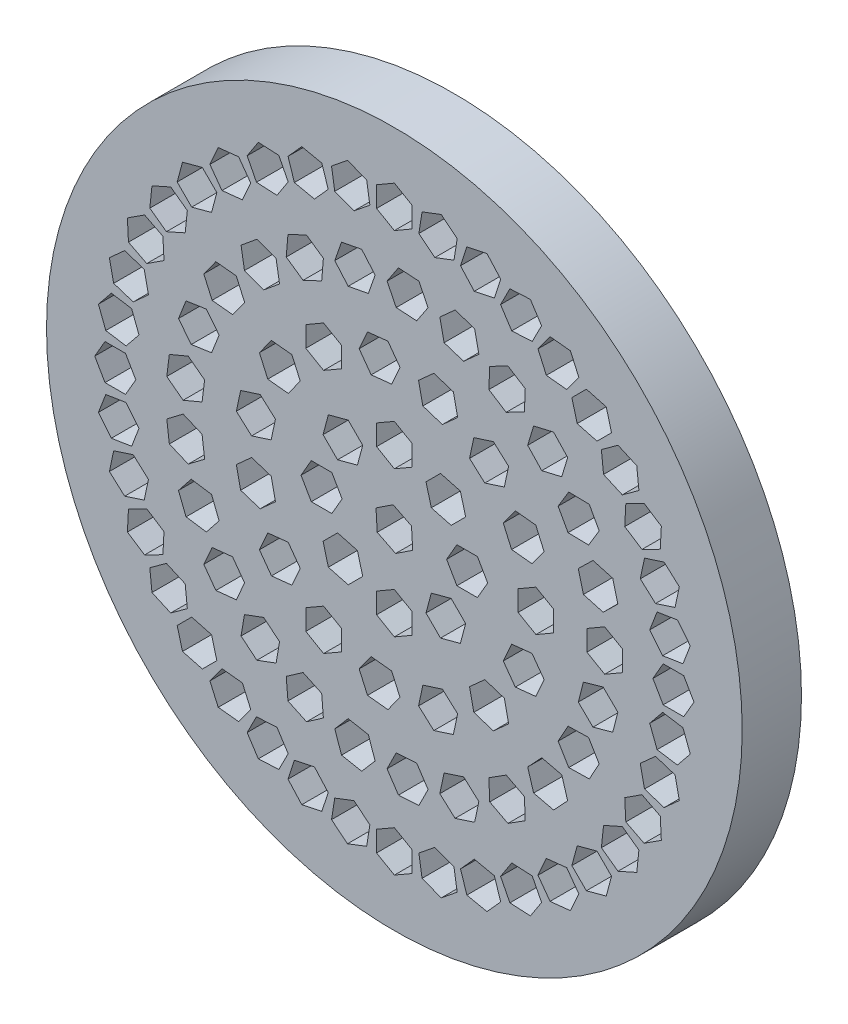
from build123d import *

# Parameters (mm, degrees)
SKETCH1_R           = 29.34
BOSS_EXTRUDE1_DEPTH = 5


with BuildPart() as part:
    # Sketch1 → Boss-Extrude1 (new body)
    with BuildSketch(Plane.XY):
        Circle(SKETCH1_R)
        Polygon((3.116890765, -3.116890765), (2.668603029, -4.789923373), (3.8933479, -6.014668244), (5.566380508, -5.566380508), (6.014668244, -3.8933479), (4.789923373, -2.668603029), align=None, mode=Mode.SUBTRACT)
        Polygon((7.872050808, 0), (7.006025404, 1.5), (5.273974596, 1.5), (4.407949192, 0), (5.273974596, -1.5), (7.006025404, -1.5), align=None, mode=Mode.SUBTRACT)
        Polygon((11.94, -1.732050808), (13.44, -0.866025404), (13.44, 0.866025404), (11.94, 1.732050808), (10.44, 0.866025404), (10.44, -0.866025404), align=None, mode=Mode.SUBTRACT)
        Polygon((17.74, -1.732050808), (19.24, -0.866025404), (19.24, 0.866025404), (17.74, 1.732050808), (16.24, 0.866025404), (16.24, -0.866025404), align=None, mode=Mode.SUBTRACT)
        Polygon((21.807949192, 0), (22.673974596, -1.5), (24.406025404, -1.5), (25.272050808, 0), (24.406025404, 1.5), (22.673974596, 1.5), align=None, mode=Mode.SUBTRACT)
        Polygon((0, -4.407949192), (-1.5, -5.273974596), (-1.5, -7.006025404), (0, -7.872050808), (1.5, -7.006025404), (1.5, -5.273974596), align=None, mode=Mode.SUBTRACT)
        Polygon((-3.116890765, -3.116890765), (-4.789923373, -2.668603029), (-6.014668244, -3.8933479), (-5.566380508, -5.566380508), (-3.8933479, -6.014668244), (-2.668603029, -4.789923373), align=None, mode=Mode.SUBTRACT)
        Polygon((-4.407949192, 0), (-5.273974596, 1.5), (-7.006025404, 1.5), (-7.872050808, 0), (-7.006025404, -1.5), (-5.273974596, -1.5), align=None, mode=Mode.SUBTRACT)
        Polygon((-3.116890765, 3.116890765), (-2.668603029, 4.789923373), (-3.8933479, 6.014668244), (-5.566380508, 5.566380508), (-6.014668244, 3.8933479), (-4.789923373, 2.668603029), align=None, mode=Mode.SUBTRACT)
        Polygon((0, 4.407949192), (1.5, 5.273974596), (1.5, 7.006025404), (0, 7.872050808), (-1.5, 7.006025404), (-1.5, 5.273974596), align=None, mode=Mode.SUBTRACT)
        Polygon((3.116890765, 3.116890765), (4.789923373, 2.668603029), (6.014668244, 3.8933479), (5.566380508, 5.566380508), (3.8933479, 6.014668244), (2.668603029, 4.789923373), align=None, mode=Mode.SUBTRACT)
        Polygon((9.185170312, -5.037484128), (10.203244233, -6.438742666), (11.925806685, -6.257694057), (12.630295216, -4.675386909), (11.612221295, -3.274128371), (9.889658843, -3.45517698), align=None, mode=Mode.SUBTRACT)
        Polygon((1.549193338, -0.774596669), (1.445417062, 0.954342452), (-0.103776276, 1.728939121), (-1.549193338, 0.774596669), (-1.445417062, -0.954342452), (0.103776276, -1.728939121), align=None, mode=Mode.SUBTRACT)
        Polygon((6.342141233, -8.337916082), (6.702254845, -10.032117423), (8.349533052, -10.567350558), (9.636697647, -9.408382351), (9.276584035, -7.714181009), (7.629305828, -7.178947874), align=None, mode=Mode.SUBTRACT)
        Polygon((2.402498318, -10.196646597), (2.042384706, -11.890847939), (3.329549301, -13.049816146), (4.976827508, -12.514583012), (5.33694112, -10.82038167), (4.049776525, -9.661413463), align=None, mode=Mode.SUBTRACT)
        Polygon((-1.952558383, -10.292284283), (-2.970632303, -11.693542821), (-2.266143772, -13.275849969), (-0.54358132, -13.456898578), (0.474492601, -12.05564004), (-0.229995931, -10.473332892), align=None, mode=Mode.SUBTRACT)
        Polygon((-5.97, -8.608292514), (-7.47, -9.474317917), (-7.47, -11.206368725), (-5.97, -12.072394129), (-4.47, -11.206368725), (-4.47, -9.474317917), align=None, mode=Mode.SUBTRACT)
        Polygon((-8.955174382, -5.435848765), (-10.677736834, -5.616897374), (-11.382225365, -7.199204522), (-10.364151444, -8.60046306), (-8.641588992, -8.419414451), (-7.937100461, -6.837107303), align=None, mode=Mode.SUBTRACT)
        Polygon((-10.391917758, -1.323497381), (-12.039195965, -0.788264247), (-13.32636056, -1.947232454), (-12.966246948, -3.641433795), (-11.318968741, -4.17666693), (-10.031804146, -3.017698723), align=None, mode=Mode.SUBTRACT)
        Polygon((-10.031804146, 3.017698723), (-11.318968741, 4.17666693), (-12.966246948, 3.641433795), (-13.32636056, 1.947232454), (-12.039195965, 0.788264247), (-10.391917758, 1.323497381), align=None, mode=Mode.SUBTRACT)
        Polygon((-7.937100461, 6.837107303), (-8.641588992, 8.419414451), (-10.364151444, 8.60046306), (-11.382225365, 7.199204522), (-10.677736834, 5.616897374), (-8.955174382, 5.435848765), align=None, mode=Mode.SUBTRACT)
        Polygon((-4.47, 9.474317917), (-4.47, 11.206368725), (-5.97, 12.072394129), (-7.47, 11.206368725), (-7.47, 9.474317917), (-5.97, 8.608292514), align=None, mode=Mode.SUBTRACT)
        Polygon((-0.229995931, 10.473332892), (0.474492601, 12.05564004), (-0.54358132, 13.456898578), (-2.266143772, 13.275849969), (-2.970632303, 11.693542821), (-1.952558383, 10.292284283), align=None, mode=Mode.SUBTRACT)
        Polygon((4.049776525, 9.661413463), (5.33694112, 10.82038167), (4.976827508, 12.514583012), (3.329549301, 13.049816146), (2.042384706, 11.890847939), (2.402498318, 10.196646597), align=None, mode=Mode.SUBTRACT)
        Polygon((7.629305828, 7.178947874), (9.276584035, 7.714181009), (9.636697647, 9.408382351), (8.349533052, 10.567350558), (6.702254845, 10.032117423), (6.342141233, 8.337916082), align=None, mode=Mode.SUBTRACT)
        Polygon((9.889658843, 3.45517698), (11.612221295, 3.274128371), (12.630295216, 4.675386909), (11.925806685, 6.257694057), (10.203244233, 6.438742666), (9.185170312, 5.037484128), align=None, mode=Mode.SUBTRACT)
        Polygon((16.751921759, -6.089393845), (18.42016826, -5.623611052), (18.85091178, -3.945975806), (17.613408798, -2.734123352), (15.945162297, -3.199906144), (15.514418777, -4.877541391), align=None, mode=Mode.SUBTRACT)
        Polygon((14.711258664, -10.064117871), (16.442929604, -10.027844536), (17.277351444, -8.510036843), (16.380102344, -7.028502486), (14.648431404, -7.064775821), (13.814009564, -8.582583514), align=None, mode=Mode.SUBTRACT)
        Polygon((11.746233083, -13.406476359), (13.432521208, -13.801991668), (14.618191575, -12.539380968), (14.117573818, -10.881254959), (12.431285693, -10.48573965), (11.245615326, -11.74835035), align=None, mode=Mode.SUBTRACT)
        Polygon((8.043148478, -15.906456631), (9.578098103, -16.708908903), (11.040516968, -15.78082967), (10.967986208, -14.050298165), (9.433036583, -13.247845894), (7.970617718, -14.175925127), align=None, mode=Mode.SUBTRACT)
        Polygon((3.834683273, -17.406975734), (5.121847868, -18.565943941), (6.769126075, -18.030710806), (7.129239687, -16.336509464), (5.842075092, -15.177541257), (4.194796885, -15.712774392), align=None, mode=Mode.SUBTRACT)
        Polygon((-0.614729184, -17.813750532), (0.343773095, -19.25641244), (2.072406096, -19.14765607), (2.842536817, -17.596237792), (1.884034538, -16.153575885), (0.155401537, -16.262332255), align=None, mode=Mode.SUBTRACT)
        Polygon((-5.025515947, -17.101221871), (-4.455902206, -18.736929725), (-2.75453078, -19.061483683), (-1.622773095, -17.750329785), (-2.192386836, -16.11462193), (-3.893758262, -15.790067973), align=None, mode=Mode.SUBTRACT)
        Polygon((-9.120531059, -15.314160545), (-8.975596783, -17.040136807), (-7.408390356, -17.777608172), (-5.986118205, -16.789103277), (-6.131052482, -15.063127015), (-7.698258908, -14.325655649), align=None, mode=Mode.SUBTRACT)
        Polygon((-12.642469663, -12.564854191), (-12.931321605, -14.272649423), (-11.596753521, -15.376700159), (-9.973333494, -14.772955663), (-9.684481551, -13.065160431), (-11.019049636, -11.961109695), align=None, mode=Mode.SUBTRACT)
        Polygon((-15.370035401, -9.026051837), (-16.074523932, -10.608358985), (-15.056450011, -12.009617523), (-13.333887559, -11.828568914), (-12.629399028, -10.246261766), (-13.647472949, -8.845003228), align=None, mode=Mode.SUBTRACT)
        Polygon((-17.131845288, -4.920109451), (-18.207704803, -6.277506337), (-17.570094374, -7.88792645), (-15.856624431, -8.140949678), (-14.780764916, -6.783552792), (-15.418375345, -5.173132679), align=None, mode=Mode.SUBTRACT)
        Polygon((-17.81719833, -0.505018494), (-19.196828617, -1.552214879), (-18.979745089, -3.270607949), (-17.383031273, -3.941804633), (-16.003400985, -2.894608248), (-16.220484514, -1.176215178), align=None, mode=Mode.SUBTRACT)
        Polygon((-17.383031273, 3.941804633), (-18.979745089, 3.270607949), (-19.196828617, 1.552214879), (-17.81719833, 0.505018494), (-16.220484514, 1.176215178), (-16.003400985, 2.894608248), align=None, mode=Mode.SUBTRACT)
        Polygon((-15.856624431, 8.140949678), (-17.570094374, 7.88792645), (-18.207704803, 6.277506337), (-17.131845288, 4.920109451), (-15.418375345, 5.173132679), (-14.780764916, 6.783552792), align=None, mode=Mode.SUBTRACT)
        Polygon((-13.333887559, 11.828568914), (-15.056450011, 12.009617523), (-16.074523932, 10.608358985), (-15.370035401, 9.026051837), (-13.647472949, 8.845003228), (-12.629399028, 10.246261766), align=None, mode=Mode.SUBTRACT)
        Polygon((-9.973333494, 14.772955663), (-11.596753521, 15.376700159), (-12.931321605, 14.272649423), (-12.642469663, 12.564854191), (-11.019049636, 11.961109695), (-9.684481551, 13.065160431), align=None, mode=Mode.SUBTRACT)
        Polygon((-5.986118205, 16.789103277), (-7.408390356, 17.777608172), (-8.975596783, 17.040136807), (-9.120531059, 15.314160545), (-7.698258908, 14.325655649), (-6.131052482, 15.063127015), align=None, mode=Mode.SUBTRACT)
        Polygon((-1.622773095, 17.750329785), (-2.75453078, 19.061483683), (-4.455902206, 18.736929725), (-5.025515947, 17.101221871), (-3.893758262, 15.790067973), (-2.192386836, 16.11462193), align=None, mode=Mode.SUBTRACT)
        Polygon((2.842536817, 17.596237792), (2.072406096, 19.14765607), (0.343773095, 19.25641244), (-0.614729184, 17.813750532), (0.155401537, 16.262332255), (1.884034538, 16.153575885), align=None, mode=Mode.SUBTRACT)
        Polygon((7.129239687, 16.336509464), (6.769126075, 18.030710806), (5.121847868, 18.565943941), (3.834683273, 17.406975734), (4.194796885, 15.712774392), (5.842075092, 15.177541257), align=None, mode=Mode.SUBTRACT)
        Polygon((10.967986208, 14.050298165), (11.040516968, 15.78082967), (9.578098103, 16.708908903), (8.043148478, 15.906456631), (7.970617718, 14.175925127), (9.433036583, 13.247845894), align=None, mode=Mode.SUBTRACT)
        Polygon((14.117573818, 10.881254959), (14.618191575, 12.539380968), (13.432521208, 13.801991668), (11.746233083, 13.406476359), (11.245615326, 11.74835035), (12.431285693, 10.48573965), align=None, mode=Mode.SUBTRACT)
        Polygon((16.380102344, 7.028502486), (17.277351444, 8.510036843), (16.442929604, 10.027844536), (14.711258664, 10.064117871), (13.814009564, 8.582583514), (14.648431404, 7.064775821), align=None, mode=Mode.SUBTRACT)
        Polygon((17.613408798, 2.734123352), (18.85091178, 3.945975806), (18.42016826, 5.623611052), (16.751921759, 6.089393845), (15.514418777, 4.877541391), (15.945162297, 3.199906144), align=None, mode=Mode.SUBTRACT)
        Polygon((21.53945715, -3.411514866), (22.160168646, -5.028523597), (23.870895034, -5.299476039), (24.960909926, -3.953419749), (24.340198429, -2.336411017), (22.629472041, -2.065458575), align=None, mode=Mode.SUBTRACT)
        Polygon((20.740592186, -6.739026913), (21.100705798, -8.433228255), (22.747984006, -8.968461389), (24.035148601, -7.809493182), (23.675034989, -6.11529184), (22.027756782, -5.580058706), align=None, mode=Mode.SUBTRACT)
        Polygon((19.43102501, -9.900601752), (19.521673545, -11.630278844), (21.064942115, -12.416613456), (22.517562149, -11.473270976), (22.426913614, -9.743593883), (20.883645044, -8.957259272), align=None, mode=Mode.SUBTRACT)
        Polygon((17.643001509, -12.818390918), (17.4619529, -14.54095337), (18.863211438, -15.559027291), (20.445518586, -14.85453876), (20.626567195, -13.131976308), (19.225308657, -12.113902387), align=None, mode=Mode.SUBTRACT)
        Polygon((15.420548758, -15.420548758), (14.972261022, -17.093581365), (16.197005893, -18.318326237), (17.870038501, -17.870038501), (18.318326237, -16.197005893), (17.093581365, -14.972261022), align=None, mode=Mode.SUBTRACT)
        Polygon((12.818390918, -17.643001509), (12.113902387, -19.225308657), (13.131976308, -20.626567195), (14.85453876, -20.445518586), (15.559027291, -18.863211438), (14.54095337, -17.4619529), align=None, mode=Mode.SUBTRACT)
        Polygon((9.900601752, -19.43102501), (8.957259272, -20.883645044), (9.743593883, -22.426913614), (11.473270976, -22.517562149), (12.416613456, -21.064942115), (11.630278844, -19.521673545), align=None, mode=Mode.SUBTRACT)
        Polygon((6.739026913, -20.740592186), (5.580058706, -22.027756782), (6.11529184, -23.675034989), (7.809493182, -24.035148601), (8.968461389, -22.747984006), (8.433228255, -21.100705798), align=None, mode=Mode.SUBTRACT)
        Polygon((3.411514866, -21.53945715), (2.065458575, -22.629472041), (2.336411017, -24.340198429), (3.953419749, -24.960909926), (5.299476039, -23.870895034), (5.028523597, -22.160168646), align=None, mode=Mode.SUBTRACT)
        Polygon((0, -21.807949192), (-1.5, -22.673974596), (-1.5, -24.406025404), (0, -25.272050808), (1.5, -24.406025404), (1.5, -22.673974596), align=None, mode=Mode.SUBTRACT)
        Polygon((-3.411514866, -21.53945715), (-5.028523597, -22.160168646), (-5.299476039, -23.870895034), (-3.953419749, -24.960909926), (-2.336411017, -24.340198429), (-2.065458575, -22.629472041), align=None, mode=Mode.SUBTRACT)
        Polygon((-6.739026913, -20.740592187), (-8.433228255, -21.100705798), (-8.968461389, -22.747984006), (-7.809493182, -24.035148601), (-6.11529184, -23.675034989), (-5.580058706, -22.027756782), align=None, mode=Mode.SUBTRACT)
        Polygon((-9.900601752, -19.43102501), (-11.630278844, -19.521673545), (-12.416613456, -21.064942115), (-11.473270976, -22.517562149), (-9.743593883, -22.426913614), (-8.957259272, -20.883645044), align=None, mode=Mode.SUBTRACT)
        Polygon((-12.818390918, -17.643001509), (-14.54095337, -17.4619529), (-15.559027291, -18.863211438), (-14.85453876, -20.445518586), (-13.131976308, -20.626567195), (-12.113902387, -19.225308657), align=None, mode=Mode.SUBTRACT)
        Polygon((-15.420548758, -15.420548758), (-17.093581365, -14.972261022), (-18.318326237, -16.197005893), (-17.870038501, -17.870038501), (-16.197005893, -18.318326237), (-14.972261022, -17.093581365), align=None, mode=Mode.SUBTRACT)
        Polygon((-17.643001509, -12.818390918), (-19.225308657, -12.113902387), (-20.626567195, -13.131976308), (-20.445518586, -14.85453876), (-18.863211438, -15.559027291), (-17.4619529, -14.54095337), align=None, mode=Mode.SUBTRACT)
        Polygon((-19.43102501, -9.900601752), (-20.883645044, -8.957259272), (-22.426913614, -9.743593883), (-22.517562149, -11.473270976), (-21.064942115, -12.416613456), (-19.521673545, -11.630278844), align=None, mode=Mode.SUBTRACT)
        Polygon((-20.740592186, -6.739026913), (-22.027756782, -5.580058706), (-23.675034989, -6.11529184), (-24.035148601, -7.809493182), (-22.747984006, -8.968461389), (-21.100705798, -8.433228255), align=None, mode=Mode.SUBTRACT)
        Polygon((-21.53945715, -3.411514866), (-22.629472041, -2.065458575), (-24.340198429, -2.336411017), (-24.960909926, -3.953419749), (-23.870895034, -5.299476039), (-22.160168646, -5.028523597), align=None, mode=Mode.SUBTRACT)
        Polygon((-21.807949192, 0), (-22.673974596, 1.5), (-24.406025404, 1.5), (-25.272050808, 0), (-24.406025404, -1.5), (-22.673974596, -1.5), align=None, mode=Mode.SUBTRACT)
        Polygon((-21.53945715, 3.411514866), (-22.160168646, 5.028523597), (-23.870895034, 5.299476039), (-24.960909926, 3.953419749), (-24.340198429, 2.336411017), (-22.629472041, 2.065458575), align=None, mode=Mode.SUBTRACT)
        Polygon((-20.740592186, 6.739026913), (-21.100705798, 8.433228255), (-22.747984006, 8.968461389), (-24.035148601, 7.809493182), (-23.675034989, 6.11529184), (-22.027756782, 5.580058706), align=None, mode=Mode.SUBTRACT)
        Polygon((-19.43102501, 9.900601752), (-19.521673545, 11.630278844), (-21.064942115, 12.416613456), (-22.517562149, 11.473270976), (-22.426913614, 9.743593883), (-20.883645044, 8.957259272), align=None, mode=Mode.SUBTRACT)
        Polygon((-17.643001509, 12.818390918), (-17.4619529, 14.54095337), (-18.863211438, 15.559027291), (-20.445518586, 14.85453876), (-20.626567195, 13.131976308), (-19.225308657, 12.113902387), align=None, mode=Mode.SUBTRACT)
        Polygon((-15.420548758, 15.420548758), (-14.972261022, 17.093581365), (-16.197005893, 18.318326237), (-17.870038501, 17.870038501), (-18.318326237, 16.197005893), (-17.093581365, 14.972261022), align=None, mode=Mode.SUBTRACT)
        Polygon((-12.818390918, 17.643001509), (-12.113902387, 19.225308657), (-13.131976308, 20.626567195), (-14.85453876, 20.445518586), (-15.559027291, 18.863211438), (-14.54095337, 17.4619529), align=None, mode=Mode.SUBTRACT)
        Polygon((-9.900601752, 19.43102501), (-8.957259272, 20.883645044), (-9.743593883, 22.426913614), (-11.473270976, 22.517562149), (-12.416613456, 21.064942115), (-11.630278844, 19.521673545), align=None, mode=Mode.SUBTRACT)
        Polygon((-6.739026913, 20.740592186), (-5.580058706, 22.027756782), (-6.11529184, 23.675034989), (-7.809493182, 24.035148601), (-8.968461389, 22.747984006), (-8.433228255, 21.100705798), align=None, mode=Mode.SUBTRACT)
        Polygon((-3.411514866, 21.53945715), (-2.065458575, 22.629472041), (-2.336411017, 24.340198429), (-3.953419749, 24.960909926), (-5.299476039, 23.870895034), (-5.028523597, 22.160168646), align=None, mode=Mode.SUBTRACT)
        Polygon((0, 21.807949192), (1.5, 22.673974596), (1.5, 24.406025404), (0, 25.272050808), (-1.5, 24.406025404), (-1.5, 22.673974596), align=None, mode=Mode.SUBTRACT)
        Polygon((3.411514866, 21.53945715), (5.028523597, 22.160168646), (5.299476039, 23.870895034), (3.953419749, 24.960909926), (2.336411017, 24.340198429), (2.065458575, 22.629472041), align=None, mode=Mode.SUBTRACT)
        Polygon((6.739026913, 20.740592186), (8.433228255, 21.100705798), (8.968461389, 22.747984006), (7.809493182, 24.035148601), (6.11529184, 23.675034989), (5.580058706, 22.027756782), align=None, mode=Mode.SUBTRACT)
        Polygon((9.900601752, 19.43102501), (11.630278844, 19.521673545), (12.416613456, 21.064942115), (11.473270976, 22.517562149), (9.743593883, 22.426913614), (8.957259272, 20.883645044), align=None, mode=Mode.SUBTRACT)
        Polygon((12.818390918, 17.643001509), (14.54095337, 17.4619529), (15.559027291, 18.863211438), (14.85453876, 20.445518586), (13.131976308, 20.626567195), (12.113902387, 19.225308657), align=None, mode=Mode.SUBTRACT)
        Polygon((15.420548758, 15.420548758), (17.093581365, 14.972261022), (18.318326237, 16.197005893), (17.870038501, 17.870038501), (16.197005893, 18.318326237), (14.972261022, 17.093581365), align=None, mode=Mode.SUBTRACT)
        Polygon((17.643001509, 12.818390918), (19.225308657, 12.113902387), (20.626567195, 13.131976308), (20.445518586, 14.85453876), (18.863211438, 15.559027291), (17.4619529, 14.54095337), align=None, mode=Mode.SUBTRACT)
        Polygon((19.43102501, 9.900601752), (20.883645044, 8.957259272), (22.426913614, 9.743593883), (22.517562149, 11.473270976), (21.064942115, 12.416613456), (19.521673545, 11.630278844), align=None, mode=Mode.SUBTRACT)
        Polygon((20.740592186, 6.739026913), (22.027756782, 5.580058706), (23.675034989, 6.11529184), (24.035148601, 7.809493182), (22.747984006, 8.968461389), (21.100705798, 8.433228255), align=None, mode=Mode.SUBTRACT)
        Polygon((21.53945715, 3.411514866), (22.629472041, 2.065458575), (24.340198429, 2.336411017), (24.960909926, 3.953419749), (23.870895034, 5.299476039), (22.160168646, 5.028523597), align=None, mode=Mode.SUBTRACT)
    extrude(amount=BOSS_EXTRUDE1_DEPTH)


solid = part.part
